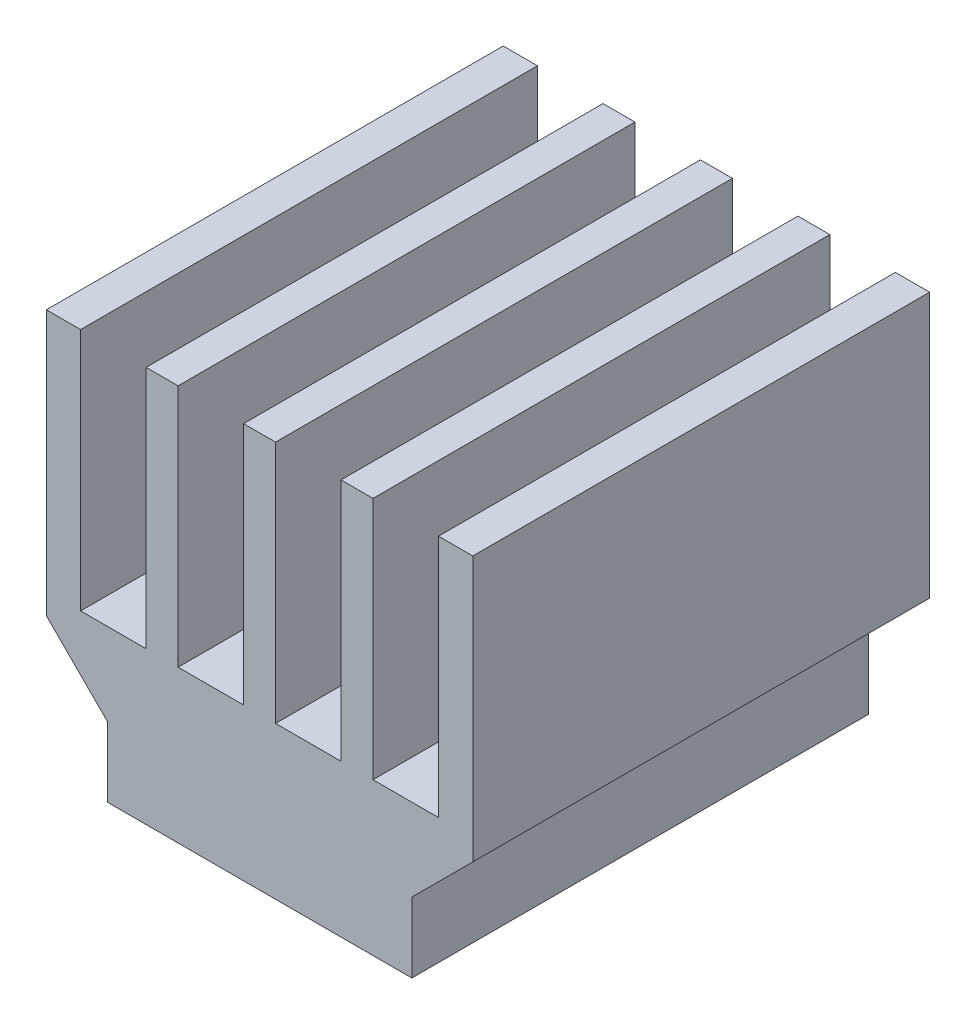
from build123d import *

# Parameters (mm, degrees)
BOSS_EXTRUDE1_DEPTH = 15


with BuildPart() as part:
    # Sketch1 → Boss-Extrude1 (new body)
    with BuildSketch(Plane.XY):
        Polygon((-5.875, 13), (-7, 13), (-7, 4.3), (-5, 2.3), (-5, 0), (5, 0), (5, 2.3), (7, 4.3), (7, 13), (5.875, 13), (5.875, 5), (3.725, 5), (3.725, 13), (2.675, 13), (2.675, 5), (0.525, 5), (0.525, 13), (-0.525, 13), (-0.525, 5), (-2.675, 5), (-2.675, 13), (-3.725, 13), (-3.725, 5), (-5.875, 5), align=None)
    extrude(amount=BOSS_EXTRUDE1_DEPTH)


solid = part.part
